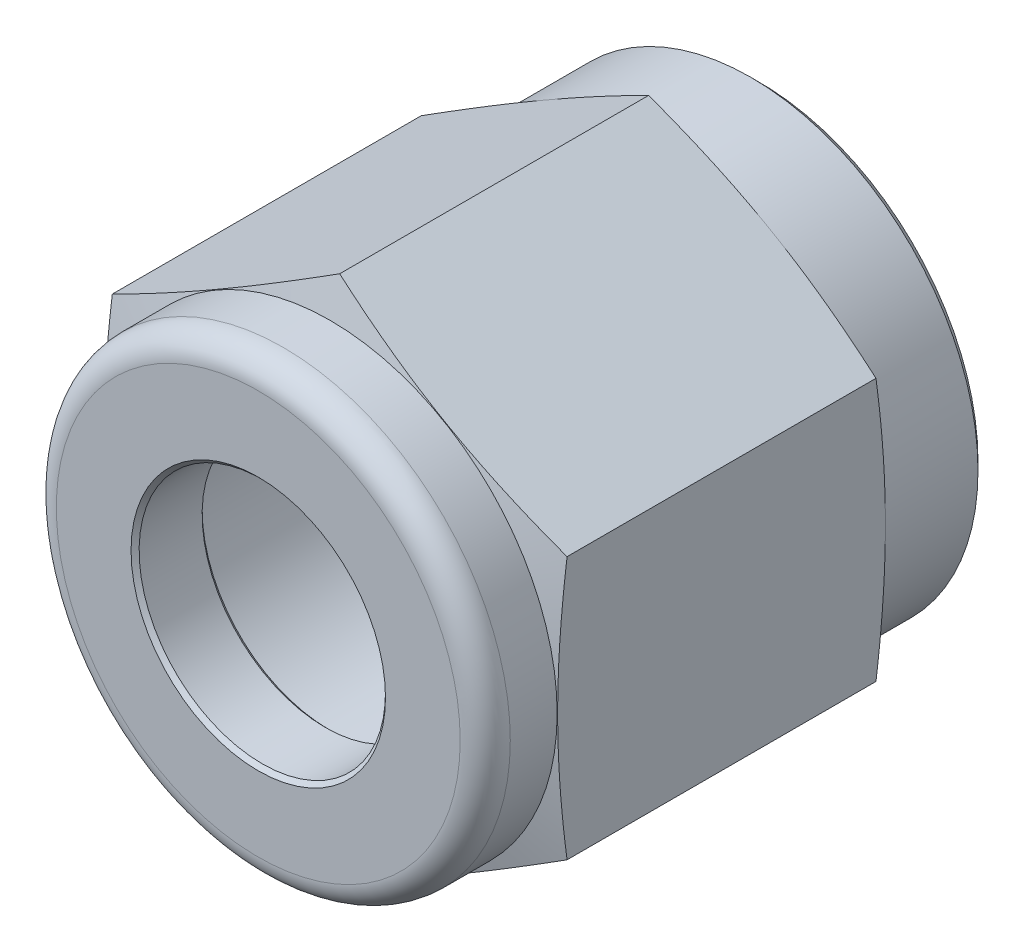
from build123d import *

# Parameters (mm, degrees)
BOSS_EXTRUDE1_DEPTH = 15.748
FILLET1_R           = 0.7874
CHAMFER1_SIZE       = 0.254
CHAMFER2_SIZE       = 0.127


with BuildPart() as part:
    # Sketch1 → Boss-Extrude1 (new body)
    with BuildSketch(Plane.XY):
        Polygon((0, 8.256224319), (-7.1501, 4.12811216), (-7.1501, -4.12811216), (0, -8.256224319), (7.1501, -4.12811216), (7.1501, 4.12811216), align=None)
    extrude(amount=BOSS_EXTRUDE1_DEPTH)

    # Sketch2 → Cut-Revolve1 (revolve, cut)
    with BuildSketch(Plane(origin=(0, 0, 0), x_dir=(0, 0, -1), z_dir=(1, 0, 0))):
        Polygon((-15.748, 9.375048639), (-15.748, 7.1374), (-13.4874, 7.1374), (-13.187611927, 8.256224319), (-3.474788073, 8.256224319), (-3.175, 7.1374), (0, 7.1374), (0, 9.375048639), align=None)
        with BuildLine():
            Line((-15.748, 3.8735), (-15.748, 0))
            Line((-15.748, 0), (0, 0))
            Line((0, 0), (0, 4.782916378))
            Line((0, 4.782916378), (-13.2588, 4.782916378))
            ThreePointArc((-13.2588, 4.782916378), (-13.438405122, 4.7085215), (-13.5128, 4.528916378))
            Line((-13.5128, 4.528916378), (-13.5128, 3.8735))
            Line((-13.5128, 3.8735), (-15.748, 3.8735))
        make_face()
    revolve(axis=Axis((0, 0, 0), (0, 0, 1)), mode=Mode.SUBTRACT)

    # Fillet1
    fillet1_edges = [part.edges().sort_by_distance(p)[0] for p in [
        (0, -7.1374, 15.748),
    ]]
    fillet(fillet1_edges, radius=FILLET1_R)

    # Chamfer1
    chamfer1_edges = [part.edges().sort_by_distance(p)[0] for p in [
        (0, -7.1374, 0),
    ]]
    chamfer(chamfer1_edges, length=CHAMFER1_SIZE)

    # Chamfer2
    chamfer2_edges = [part.edges().sort_by_distance(p)[0] for p in [
        (0, -3.8735, 15.748),
        (0, -3.8735, 13.5128),
    ]]
    chamfer(chamfer2_edges, length=CHAMFER2_SIZE)


solid = part.part
